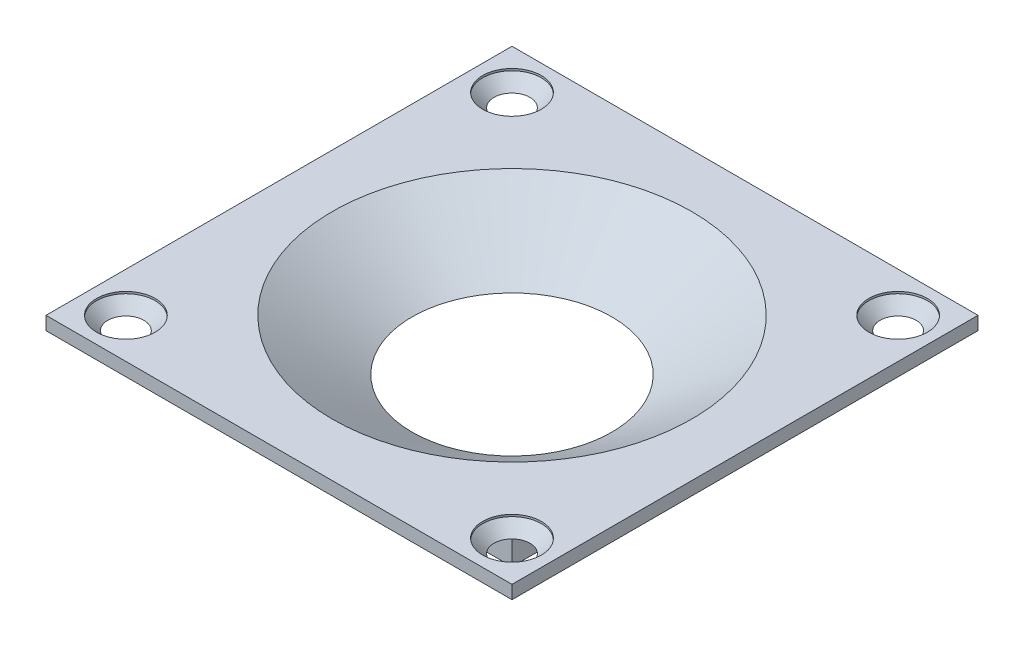
from build123d import *

# Parameters (mm, degrees)
SKETCH1_W                                      = 25
SKETCH1_H                                      = 25
BOSS_EXTRUDE1_DEPTH                            = 2.85
SKETCH2_W                                      = 35
SKETCH2_H                                      = 35
BOSS_EXTRUDE2_DEPTH                            = 1
CSK_FOR_M2_FLAT_HEAD_MACHINE_SCREW1_AT_2_COUNT = 2
CSK_FOR_M2_FLAT_HEAD_MACHINE_SCREW1_AT_2_PITCH = 29
CSK_FOR_M2_FLAT_HEAD_MACHINE_SCREW1_AT_3_COUNT = 2
CSK_FOR_M2_FLAT_HEAD_MACHINE_SCREW1_AT_3_PITCH = 41.012193309
CSK_FOR_M2_FLAT_HEAD_MACHINE_SCREW1_AT_4_COUNT = 2
CSK_FOR_M2_FLAT_HEAD_MACHINE_SCREW1_AT_4_PITCH = 29


with BuildPart() as part:
    # Sketch1 → Boss-Extrude1 (new body)
    with BuildSketch(Plane(origin=(0, 0, 0), x_dir=(1, 0, 0), z_dir=(0, 1, 0))):
        Rectangle(SKETCH1_W, SKETCH1_H)
    extrude(amount=BOSS_EXTRUDE1_DEPTH)

    # Sketch2 → Boss-Extrude2 (add)
    with BuildSketch(Plane(origin=(0, 2.85, 0), x_dir=(1, 0, 0), z_dir=(0, 1, 0))):
        Rectangle(SKETCH2_W, SKETCH2_H)
    extrude(amount=BOSS_EXTRUDE2_DEPTH)

    # Sketch3 → Cut-Revolve1 (revolve, cut)
    with BuildSketch(Plane.XY):
        Polygon((0, 0), (7.5, 0), (13.5, 3.85), (0, 3.85), align=None)
    revolve(axis=Axis((0, 0, 0), (0, 1, 0)), mode=Mode.SUBTRACT)

    # Sketch4 → CSK for M2 Flat Head Machine Screw1 (revolve, cut)
    with BuildSketch(Plane(origin=(-14.5, 3.85, -14.5), x_dir=(0, 0, 1), z_dir=(1, 0, 0))):
        Polygon((0, 0), (0, 10.721032743), (1.2, 10), (1.2, 1.15), (2.2, 0.15), (2.2, 0), align=None)
    csk_for_m2_flat_head_machine_screw1 = revolve(axis=Axis((-14.5, 10.2, -14.5), (0, -1, 0)), mode=Mode.SUBTRACT)

    # CSK for M2 Flat Head Machine Screw1 at 2: CSK for M2 Flat Head Machine Screw1 ×2
    with Locations(*[(i * CSK_FOR_M2_FLAT_HEAD_MACHINE_SCREW1_AT_2_PITCH, 0, 0) for i in range(1, CSK_FOR_M2_FLAT_HEAD_MACHINE_SCREW1_AT_2_COUNT)]):
        add(csk_for_m2_flat_head_machine_screw1, mode=Mode.SUBTRACT)

    # CSK for M2 Flat Head Machine Screw1 at 3: CSK for M2 Flat Head Machine Screw1 ×2
    with Locations(*[Vector(0.707106781, 0, 0.707106781) * (i * CSK_FOR_M2_FLAT_HEAD_MACHINE_SCREW1_AT_3_PITCH) for i in range(1, CSK_FOR_M2_FLAT_HEAD_MACHINE_SCREW1_AT_3_COUNT)]):
        add(csk_for_m2_flat_head_machine_screw1, mode=Mode.SUBTRACT)

    # CSK for M2 Flat Head Machine Screw1 at 4: CSK for M2 Flat Head Machine Screw1 ×2
    with Locations(*[(0, 0, i * CSK_FOR_M2_FLAT_HEAD_MACHINE_SCREW1_AT_4_PITCH) for i in range(1, CSK_FOR_M2_FLAT_HEAD_MACHINE_SCREW1_AT_4_COUNT)]):
        add(csk_for_m2_flat_head_machine_screw1, mode=Mode.SUBTRACT)


solid = part.part
